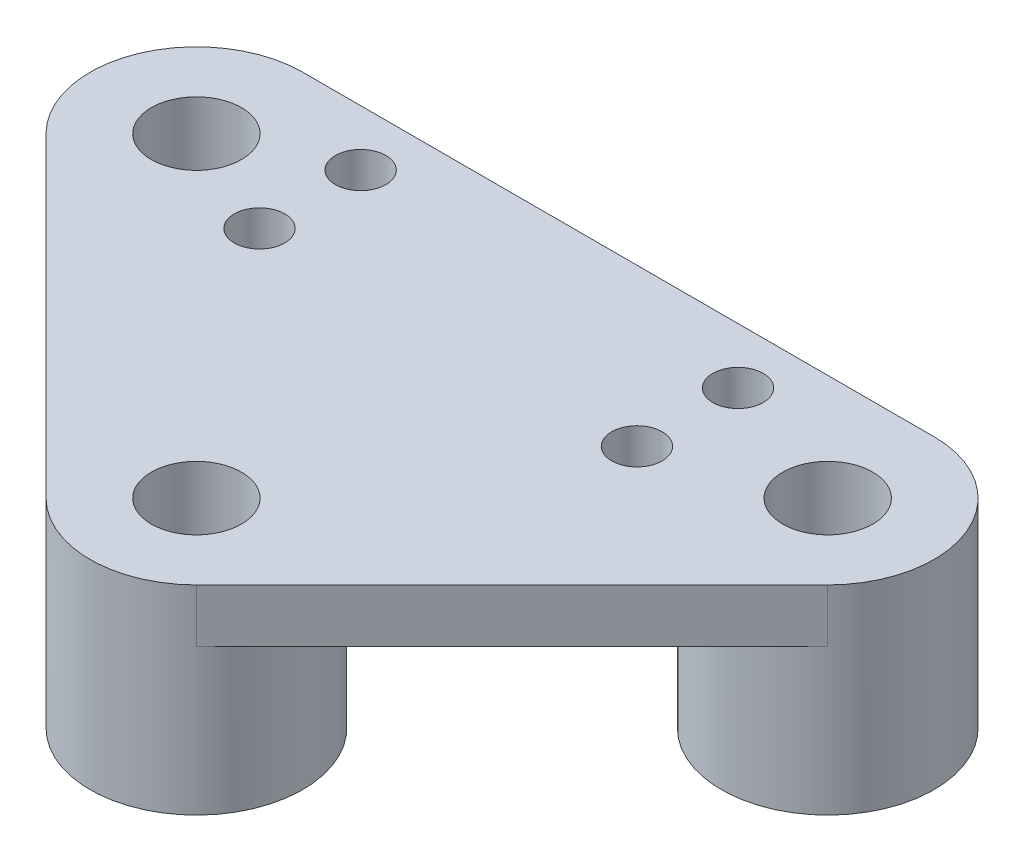
from build123d import *

# Parameters (mm, degrees)
BOSS_EXTRUDE1_DEPTH       = 2.54
SKETCH2_R                 = 5.08
BOSS_EXTRUDE2_DEPTH       = 6.985
F_6_CLEARANCE_HOLE1_D     = 4.3053
TAP_DRILL_FOR_4_40_TAP1_D = 2.413


with BuildPart() as part:
    # Sketch1 → Boss-Extrude1 (new body)
    with BuildSketch(Plane(origin=(0, 0, 0), x_dir=(1, 0, 0), z_dir=(0, 1, 0))):
        with BuildLine():
            Line((-15.08125, 5.08), (15.08125, 5.08))
            ThreePointArc((15.08125, 5.08), (19.774558025, 1.944031836), (18.673352448, -3.592102448))
            Line((18.673352448, -3.592102448), (3.592102448, -18.673352448))
            ThreePointArc((3.592102448, -18.673352448), (0, -20.16125), (-3.592102448, -18.673352448))
            Line((-3.592102448, -18.673352448), (-18.673352448, -3.592102448))
            ThreePointArc((-18.673352448, -3.592102448), (-19.774558025, 1.944031836), (-15.08125, 5.08))
        make_face()
    extrude(amount=BOSS_EXTRUDE1_DEPTH)

    # Sketch2 → Boss-Extrude2 (add)
    with BuildSketch(Plane.XZ):
        with Locations((-15.08125, 0)):
            Circle(SKETCH2_R)
        with Locations((0, 15.08125)):
            Circle(SKETCH2_R)
        with Locations((15.08125, 0)):
            Circle(SKETCH2_R)
    extrude(amount=BOSS_EXTRUDE2_DEPTH)

    # #6 Clearance Hole1 (through all)
    with Locations(Plane(origin=(0, 2.54, 0), x_dir=(1, 0, 0), z_dir=(0, 1, 0))):
        with Locations((-15.08125, 0), (0, -15.08125), (15.08125, 0)):
            Hole(F_6_CLEARANCE_HOLE1_D / 2)

    # Tap Drill for #4-40 Tap1 (through all)
    with Locations(Plane(origin=(0, 2.54, 0), x_dir=(1, 0, 0), z_dir=(0, 1, 0))):
        with Locations((8.380000004, -2.414999996), (8.380000004, 2.414999996), (-9.650000004, -2.414999996), (-9.650000004, 2.414999996)):
            Hole(TAP_DRILL_FOR_4_40_TAP1_D / 2)


solid = part.part
